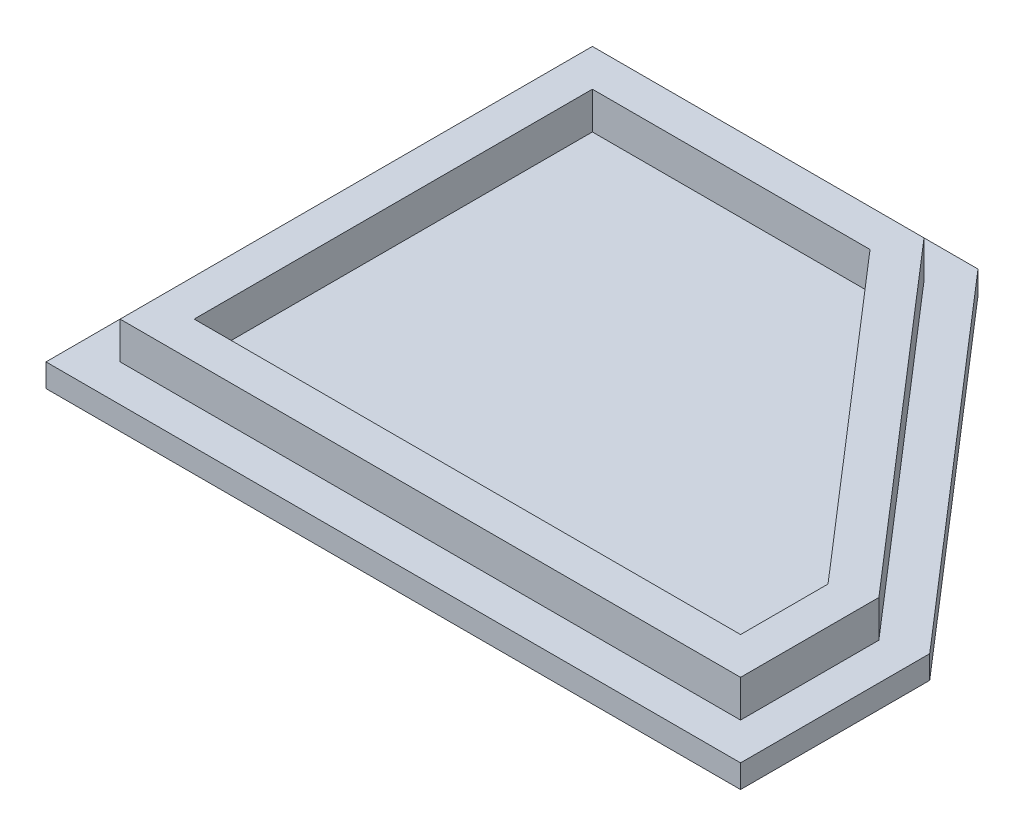
from build123d import *

# Parameters (mm, degrees)
BOSS_EXTRUDE2_DEPTH = 2.5
BOSS_EXTRUDE3_DEPTH = 4


with BuildPart() as part:
    # Sketch1 → Boss-Extrude2 (new body)
    with BuildSketch(Plane(origin=(0, 0, 0), x_dir=(1, 0, 0), z_dir=(0, 1, 0))):
        Polygon((-52.914786993, 31.596385048), (-11.274786993, 31.596385048), (22.085213007, -6.979648962), (22.085213007, -27.403614952), (-52.914786993, -27.403614952), align=None)
    extrude(amount=BOSS_EXTRUDE2_DEPTH)

    # Sketch2 → Boss-Extrude3 (add)
    with BuildSketch(Plane(origin=(0, 2.5, 0), x_dir=(1, 0, 0), z_dir=(0, 1, 0))):
        Polygon((18.085213007, -23.403614952), (-48.914786993, -23.403614952), (-48.914786993, 27.596385048), (-13.10390193, 27.596385048), (18.085213007, -8.469333134), align=None)
        Polygon((14.085213007, -19.403614952), (-44.914786993, -19.403614952), (-44.914786993, 23.596385048), (-14.933016866, 23.596385048), (14.085213007, -9.959017305), align=None, mode=Mode.SUBTRACT)
    extrude(amount=BOSS_EXTRUDE3_DEPTH)


solid = part.part
